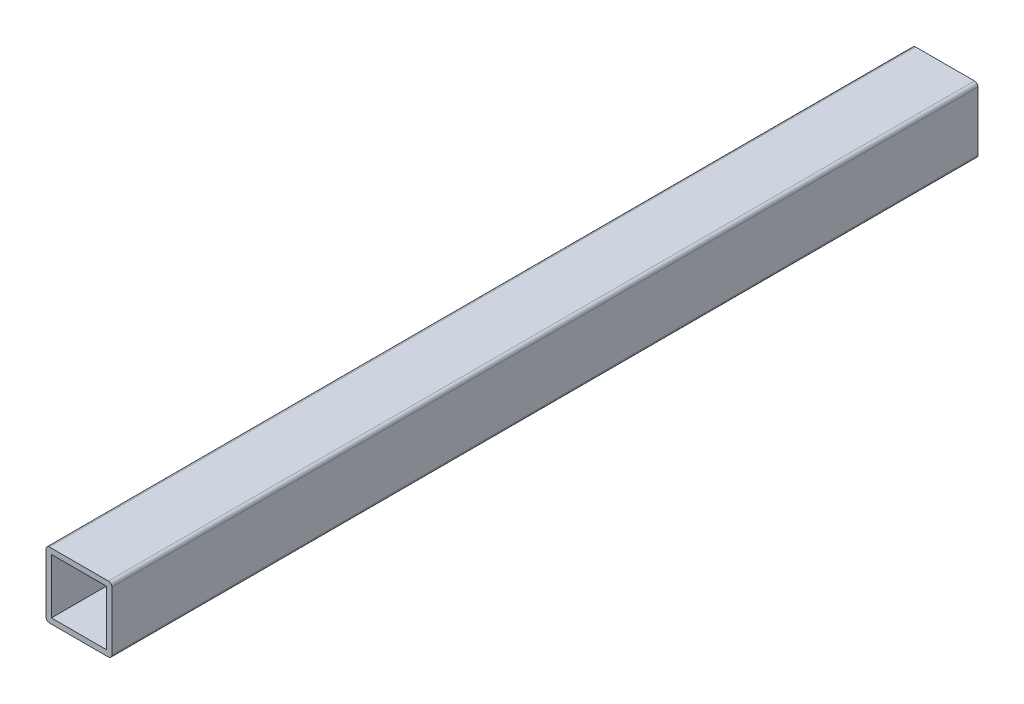
from build123d import *

# Parameters (mm, degrees)
SKETCH_1_W          = 19
SKETCH_1_H          = 19
SKETCH_1_W_2        = 15.88
SKETCH_1_H_2        = 15.88
EXTRUDE_1_DEPTH     = 900
FILLET_2_R          = 1
SKETCH_2_W          = 650
SKETCH_2_H          = 19
CUT_EXTRUDE_2_DEPTH = 51


with BuildPart() as part:
    # 스케치1 → 보스-돌출1 (new body)
    with BuildSketch(Plane.XY):
        with Locations((9.5, -9.5)):
            Rectangle(SKETCH_1_W, SKETCH_1_H)
        with Locations((9.5, -9.5)):
            Rectangle(SKETCH_1_W_2, SKETCH_1_H_2, mode=Mode.SUBTRACT)
    extrude(amount=EXTRUDE_1_DEPTH)

    # 필렛2
    fillet_2_edges = [part.edges().sort_by_distance(p)[0] for p in [
        (0, 0, 450),
        (19, 0, 450),
        (19, -19, 450),
        (0, -19, 450),
    ]]
    fillet(fillet_2_edges, radius=FILLET_2_R)

    # 스케치2 → 컷-돌출2 (cut)
    with BuildSketch(Plane(origin=(19, 0, 0), x_dir=(0, 0, -1), z_dir=(1, 0, 0))):
        with Locations((-575, -9.5)):
            Rectangle(SKETCH_2_W, SKETCH_2_H)
    extrude(amount=-CUT_EXTRUDE_2_DEPTH, mode=Mode.SUBTRACT)


solid = part.part
